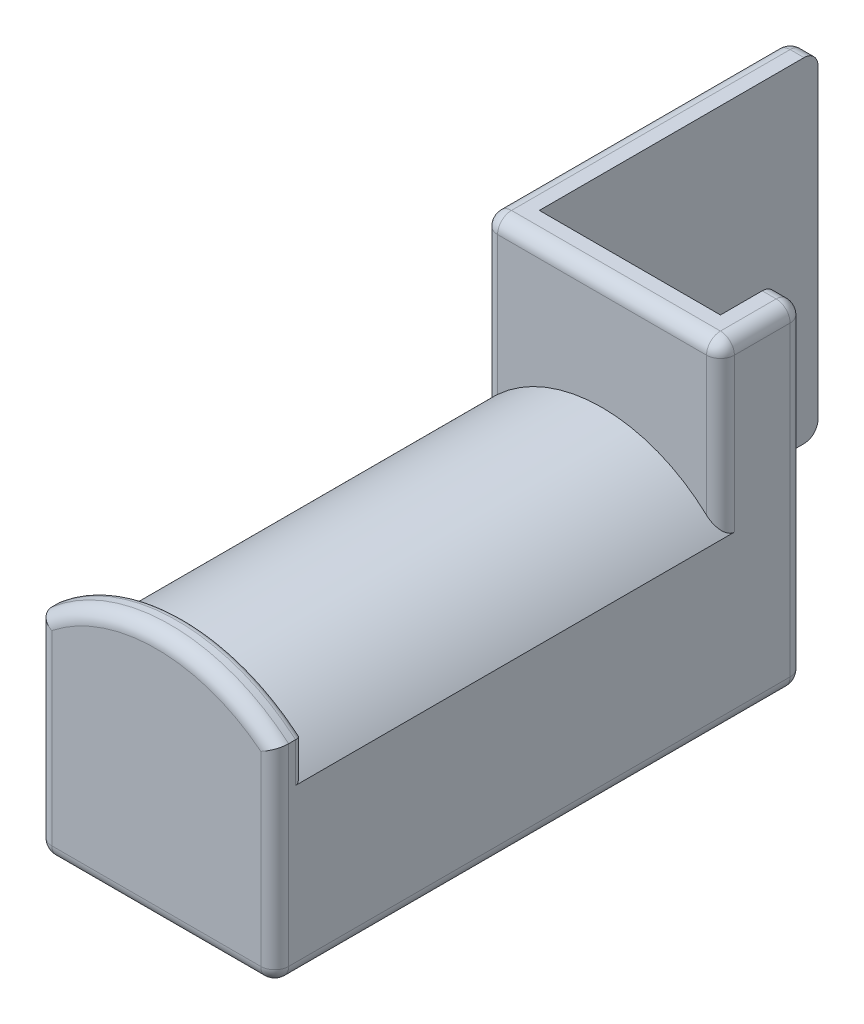
from build123d import *

# Parameters (mm, degrees)
BOSS_EXTRUDE1_DEPTH = 38.1
BOSS_EXTRUDE2_DEPTH = 47.625
BOSS_EXTRUDE3_DEPTH = 3.175
FILLET1_R           = 1.5875
FILLET2_R           = 0.79375


with BuildPart() as part:
    # Sketch1 → Boss-Extrude1 (new body)
    with BuildSketch(Plane(origin=(0, 0, 0), x_dir=(1, 0, 0), z_dir=(0, 1, 0))):
        Polygon((0, 0), (0, -34.925), (26.9875, -34.925), (26.9875, -25.4), (23.8125, -25.4), (23.8125, -31.75), (3.175, -31.75), (3.175, 0), align=None)
    extrude(amount=BOSS_EXTRUDE1_DEPTH)

    # Sketch2 → Boss-Extrude2 (add)
    with BuildSketch(Plane.XY.offset(34.925)):
        with BuildLine():
            Line((0, 19.05), (0, 0))
            Line((0, 0), (26.9875, 0))
            Line((26.9875, 0), (26.9875, 19.05))
            ThreePointArc((26.9875, 19.05), (13.49375, 25.4), (0, 19.05))
        make_face()
    extrude(amount=BOSS_EXTRUDE2_DEPTH)

    # Sketch3 → Boss-Extrude3 (add)
    with BuildSketch(Plane.XY.offset(82.55)):
        with BuildLine():
            Line((0, 19.05), (0, 23.56829895))
            ThreePointArc((0, 23.56829895), (13.49375, 28.575), (26.9875, 23.56829895))
            Line((26.9875, 23.56829895), (26.9875, 19.05))
            Line((26.9875, 19.05), (26.9875, 0))
            Line((26.9875, 0), (0, 0))
            Line((0, 0), (0, 19.05))
        make_face()
    extrude(amount=BOSS_EXTRUDE3_DEPTH)

    # Fillet1
    fillet1_edges = [part.edges().sort_by_distance(p)[0] for p in [
        (13.49375, 38.1, 34.925),
        (0, 0, 42.8625),
        (1.5875, 0, 0),
        (26.9875, 38.1, 30.1625),
        (26.9875, 19.05, 25.4),
        (26.9875, 28.575, 34.925),
        (0, 28.575, 34.925),
        (0, 19.05, 0),
        (25.4, 38.1, 25.4),
        (26.9875, 11.784149475, 85.725),
        (13.49375, 28.575, 85.725),
        (0, 11.784149475, 85.725),
        (13.49375, 0, 85.725),
        (1.5875, 38.1, 0),
        (0, 38.1, 17.4625),
        (25.4, 0, 25.4),
        (26.9875, 0, 55.5625),
    ]]
    fillet(fillet1_edges, radius=FILLET1_R)

    # Fillet2
    fillet2_edges = [part.edges().sort_by_distance(p)[0] for p in [
        (26.9875, 21.309149475, 82.55),
        (13.49375, 28.575, 82.55),
        (0, 21.309149475, 82.55),
    ]]
    fillet(fillet2_edges, radius=FILLET2_R)


solid = part.part
